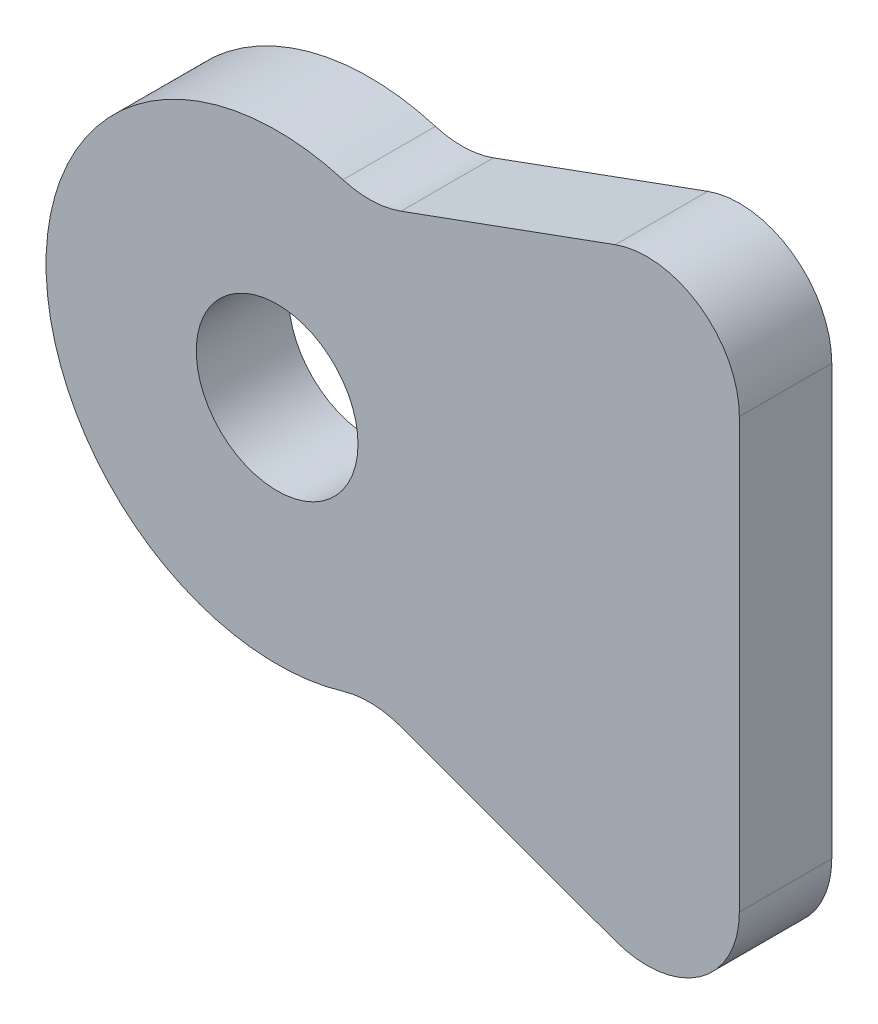
from build123d import *

# Parameters (mm, degrees)
ESQUISSE1_R        = 5
ESQUISSE1_R_2      = 1.75
BOSS_EXTRU_1_DEPTH = 2
BOSS_EXTRU_2_DEPTH = 2
CONG_1_R           = 2


with BuildPart() as part:
    # Esquisse1 → Boss.-Extru.1 (new body)
    with BuildSketch(Plane.XY):
        Circle(ESQUISSE1_R)
        Circle(ESQUISSE1_R_2, mode=Mode.SUBTRACT)
    extrude(amount=BOSS_EXTRU_1_DEPTH)

    # Esquisse2 → Boss.-Extru.2 (add)
    with BuildSketch(Plane.XY.offset(2)):
        Polygon((10, 7.5), (10, -7.5), (2, -4.582575695), (2, 4.582575695), align=None)
    extrude(amount=-BOSS_EXTRU_2_DEPTH)

    # Congé1
    cong_1_edges = [part.edges().sort_by_distance(p)[0] for p in [
        (2, 4.582575695, 1),
        (10, 7.5, 1),
        (10, -7.5, 1),
        (2, -4.582575695, 1),
    ]]
    fillet(cong_1_edges, radius=CONG_1_R)


solid = part.part
